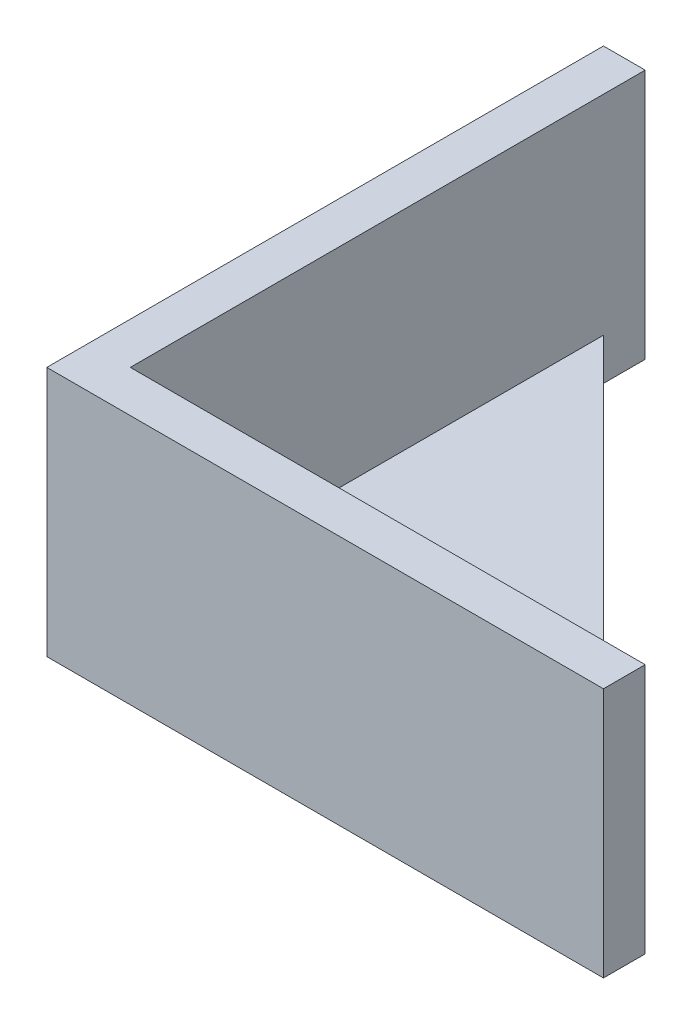
from build123d import *

# Parameters (mm, degrees)
EXTRUDE_1_DEPTH = 3
EXTRUDE_2_DEPTH = 15


with BuildPart() as part:
    # 草图1 → 凸台-拉伸1 (new body)
    with BuildSketch(Plane(origin=(0, 0, 0), x_dir=(1, 0, 0), z_dir=(0, 1, 0))):
        Polygon((3, 40), (0, 40), (3, 37), align=None)
        Polygon((0, 40), (40, 0), (0, 0), align=None)
        Polygon((37, 3), (40, 0), (40, 3), align=None)
    extrude(amount=EXTRUDE_1_DEPTH)

    # 草图2 → 凸台-拉伸2 (add)
    with BuildSketch(Plane(origin=(0, 3, 0), x_dir=(1, 0, 0), z_dir=(0, 1, 0))):
        Polygon((3, 3), (3, 40), (0, 40), (0, 0), (40, 0), (40, 3), align=None)
    extrude(amount=EXTRUDE_2_DEPTH)


solid = part.part
